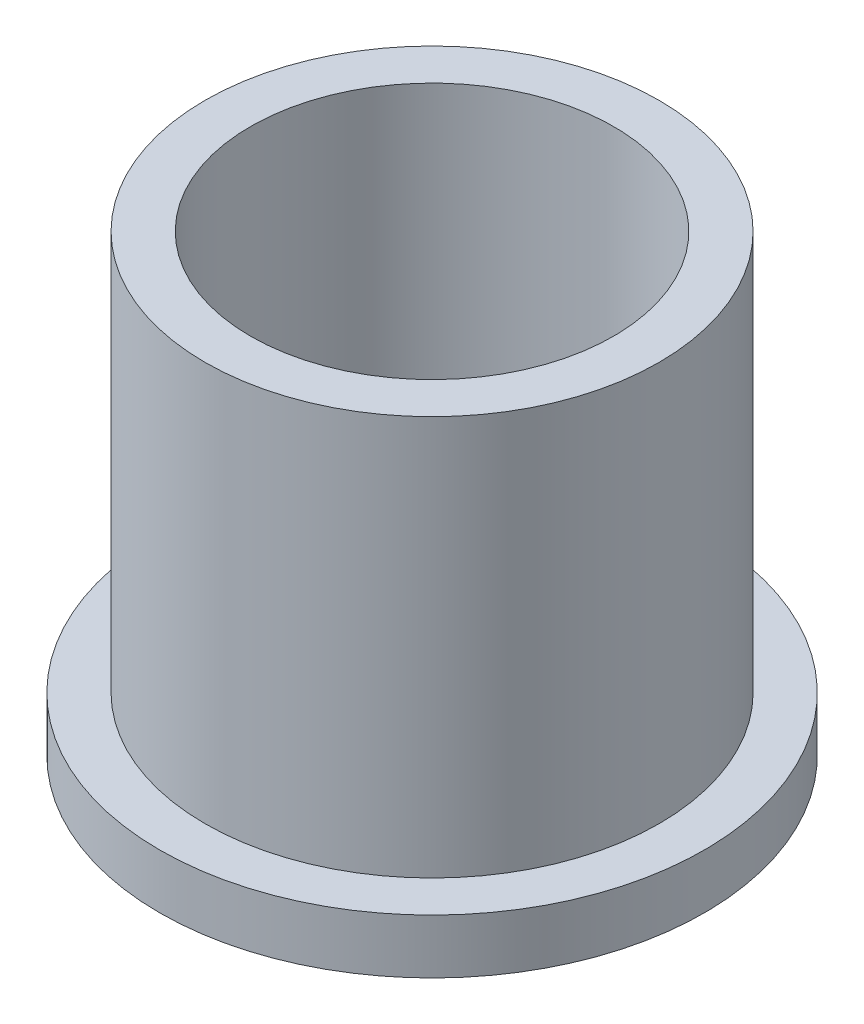
from build123d import *


with BuildPart() as part:
    # 스케치1 → 회전1 (revolve)
    with BuildSketch(Plane.XY):
        Polygon((10, 25), (12.5, 25), (12.5, 3), (15, 3), (15, 0), (10, 0), align=None)
    revolve(axis=Axis((0, 34.562566529, 0), (0, -1, 0)))


solid = part.part
